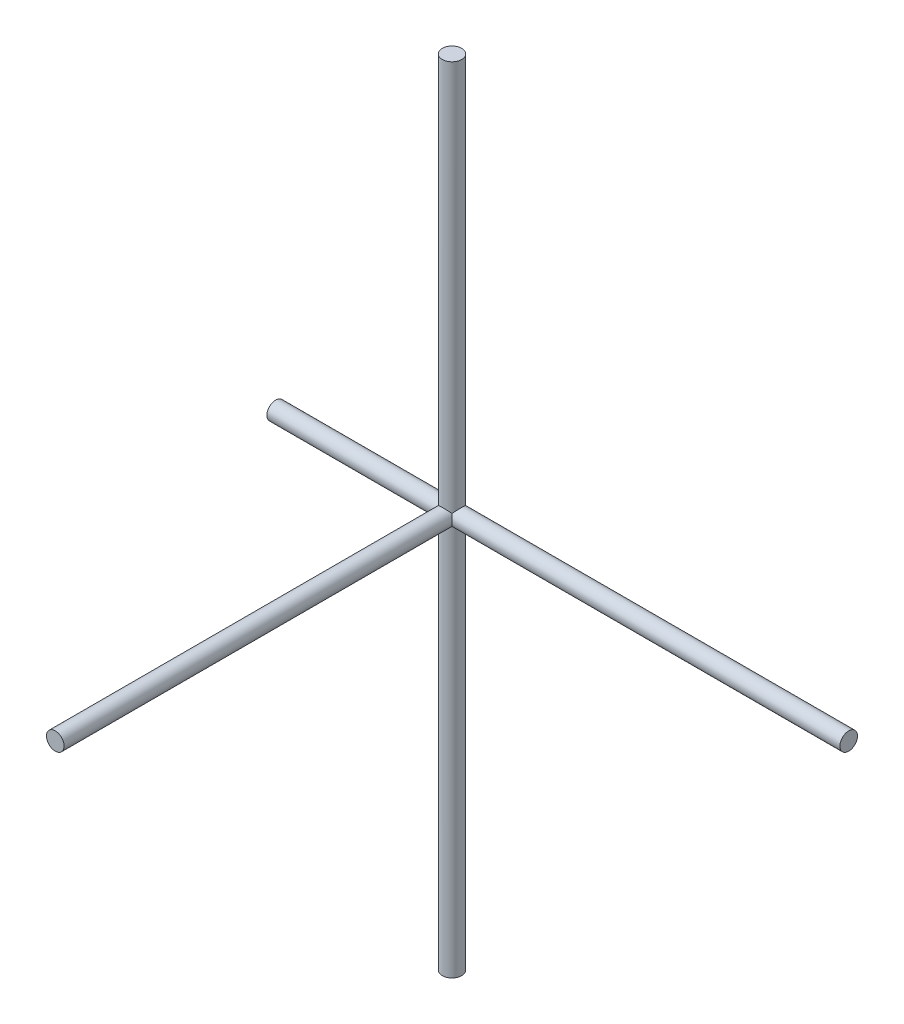
from build123d import *

# Parameters (mm, degrees)
CROQUIS1_R              = 4.4
SALIENTE_EXTRUIR1_DEPTH = 180
CROQUIS4_R              = 4.4
SALIENTE_EXTRUIR2_DEPTH = 180
CROQUIS5_R              = 4
SALIENTE_EXTRUIR3_DEPTH = 180
CROQUIS6_R              = 4
SALIENTE_EXTRUIR4_DEPTH = 80
CROQUIS7_R              = 4
SALIENTE_EXTRUIR5_DEPTH = 180


with BuildPart() as part:
    # Croquis1 → Saliente-Extruir1 (new body)
    with BuildSketch(Plane(origin=(0, 0, 0), x_dir=(1, 0, 0), z_dir=(0, 1, 0))):
        Circle(CROQUIS1_R)
    extrude(amount=SALIENTE_EXTRUIR1_DEPTH)

    # Croquis4 → Saliente-Extruir2 (add)
    with BuildSketch(Plane(origin=(0, 0, 0), x_dir=(-1, 0, 0), z_dir=(0, -1, 0))):
        Circle(CROQUIS4_R)
    extrude(amount=SALIENTE_EXTRUIR2_DEPTH)

    # Croquis5 → Saliente-Extruir3 (add)
    with BuildSketch(Plane(origin=(0, 0, 0), x_dir=(0, 0, -1), z_dir=(1, 0, 0))):
        Circle(CROQUIS5_R)
    extrude(amount=SALIENTE_EXTRUIR3_DEPTH)

    # Croquis6 → Saliente-Extruir4 (add)
    with BuildSketch(Plane(origin=(0, 0, 0), x_dir=(0, 0, -1), z_dir=(1, 0, 0))):
        Circle(CROQUIS6_R)
    extrude(amount=-SALIENTE_EXTRUIR4_DEPTH)

    # Croquis7 → Saliente-Extruir5 (add)
    with BuildSketch(Plane.XY):
        Circle(CROQUIS7_R)
    extrude(amount=SALIENTE_EXTRUIR5_DEPTH)


solid = part.part
